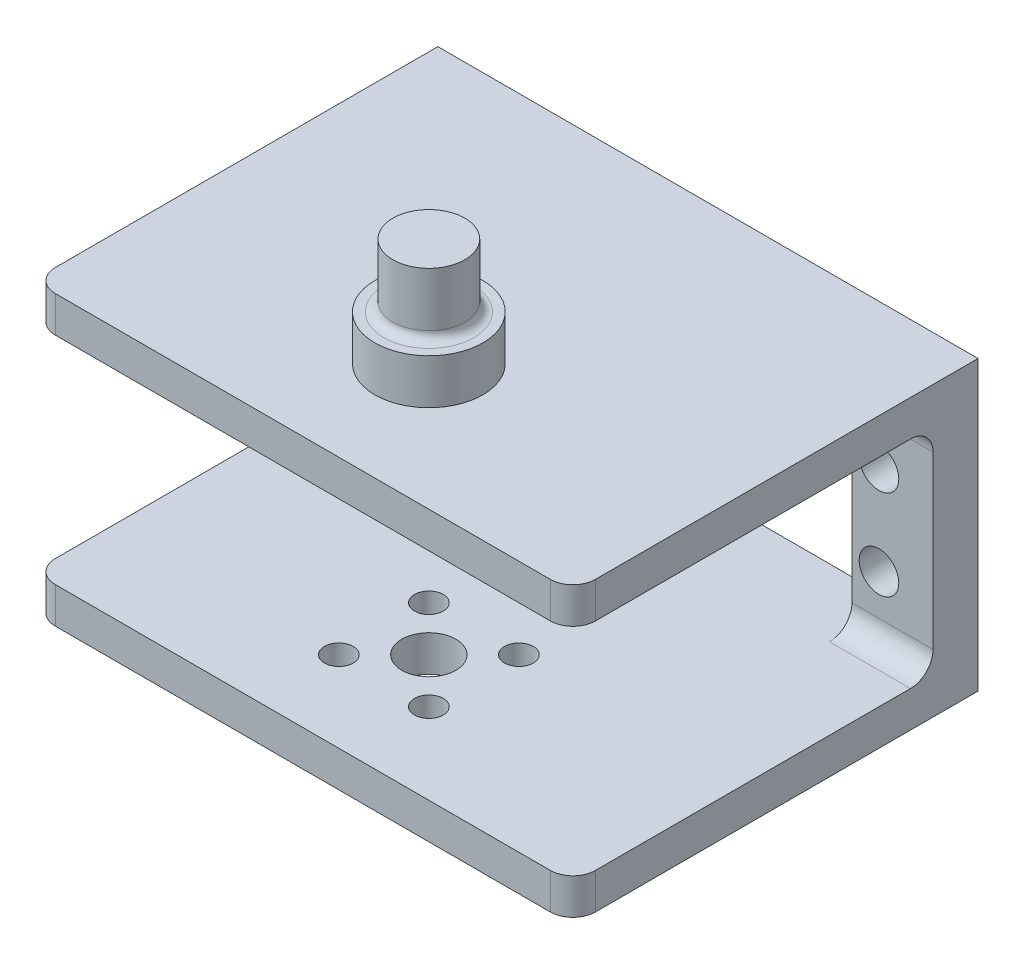
from build123d import *

# Parameters (mm, degrees)
SKETCH1_W           = 60
SKETCH1_H           = 4
BOSS_EXTRUDE1_DEPTH = 45
SKETCH1_3_W         = 9
SKETCH1_3_H         = 24
SKETCH1_3_R         = 2.2
BOSS_EXTRUDE2_DEPTH = 5
SKETCH2_R           = 3
SKETCH2_R_2         = 1.6
CUT_EXTRUDE1_DEPTH  = 124.088359511
BOSS_EXTRUDE3_DEPTH = 45
FILLET1_R           = 2.5
FILLET3_R           = 2.5
SKETCH3_R           = 4
BOSS_EXTRUDE4_DEPTH = 12
SKETCH4_R           = 6
BOSS_EXTRUDE5_DEPTH = 5
FILLET4_R           = 1


with BuildPart() as part:
    # Sketch1 → Boss-Extrude1 (new body)
    with BuildSketch(Plane.XY):
        with Locations((-82.025641026, 5.685176195)):
            Rectangle(SKETCH1_W, SKETCH1_H)
    extrude(amount=BOSS_EXTRUDE1_DEPTH)

    # Sketch1_3 → Boss-Extrude2 (add)
    # profile 1 of 2: a face of its own
    with BuildSketch(Plane.XY):
        with Locations((-107.525641026, 19.685176195)):
            Rectangle(SKETCH1_3_W, SKETCH1_3_H)
        with Locations((-106.025641026, 14.685176195)):
            Circle(SKETCH1_3_R, mode=Mode.SUBTRACT)
        with Locations((-106.025641026, 24.685176195)):
            Circle(SKETCH1_3_R, mode=Mode.SUBTRACT)
    # profile 2 of 2: a face of its own
    with BuildSketch(Plane.XY):
        with Locations((-56.525641026, 19.685176195)):
            Rectangle(SKETCH1_3_W, SKETCH1_3_H)
        with Locations((-58.025641026, 14.685176195)):
            Circle(SKETCH1_3_R, mode=Mode.SUBTRACT)
        with Locations((-58.025641026, 24.685176195)):
            Circle(SKETCH1_3_R, mode=Mode.SUBTRACT)
    extrude(amount=BOSS_EXTRUDE2_DEPTH)

    # Sketch2 → Cut-Extrude1 (cut, through all)
    with BuildSketch(Plane(origin=(0, 7.685176195, 0), x_dir=(1, 0, 0), z_dir=(0, 1, 0))):
        with Locations((-82.025641026, -31)):
            Circle(SKETCH2_R)
        with Locations((-77.025641026, -26)):
            Circle(SKETCH2_R_2)
        with Locations((-87.025641026, -26)):
            Circle(SKETCH2_R_2)
        with Locations((-77.025641026, -36)):
            Circle(SKETCH2_R_2)
        with Locations((-87.025641026, -36)):
            Circle(SKETCH2_R_2)
    extrude(amount=-CUT_EXTRUDE1_DEPTH, mode=Mode.SUBTRACT)

    # Sketch1_4 → Boss-Extrude3 (add)
    with BuildSketch(Plane.XY):
        Polygon((-112.025641026, 35.685176195), (-112.025641026, 31.685176195), (-103.025641026, 31.685176195), (-61.025641026, 31.685176195), (-52.025641026, 31.685176195), (-52.025641026, 35.685176195), align=None)
    extrude(amount=BOSS_EXTRUDE3_DEPTH)

    # Fillet1
    fillet1_edges = [part.edges().sort_by_distance(p)[0] for p in [
        (-52.025641026, 5.685176195, 45),
        (-112.025641026, 5.685176195, 45),
        (-52.025641026, 33.685176195, 45),
        (-112.025641026, 33.685176195, 45),
    ]]
    fillet(fillet1_edges, radius=FILLET1_R)

    # Fillet3
    fillet3_edges = [part.edges().sort_by_distance(p)[0] for p in [
        (-107.525641026, 7.685176195, 5),
        (-56.525641026, 7.685176195, 5),
        (-56.525641026, 31.685176195, 5),
        (-107.525641026, 31.685176195, 5),
    ]]
    fillet(fillet3_edges, radius=FILLET3_R)

    # Sketch3 → Boss-Extrude4 (add)
    with BuildSketch(Plane(origin=(0, 35.685176195, 0), x_dir=(1, 0, 0), z_dir=(0, 1, 0))):
        with Locations((-82.025641026, -31)):
            Circle(SKETCH3_R)
    extrude(amount=BOSS_EXTRUDE4_DEPTH)

    # Sketch4 → Boss-Extrude5 (add)
    with BuildSketch(Plane(origin=(0, 35.685176195, 0), x_dir=(1, 0, 0), z_dir=(0, 1, 0))):
        with Locations((-82.025641026, -31)):
            Circle(SKETCH4_R)
    extrude(amount=BOSS_EXTRUDE5_DEPTH)

    # Fillet4
    fillet4_edges = [part.edges().sort_by_distance(p)[0] for p in [
        (-86.025641026, 40.685176195, 31),
    ]]
    fillet(fillet4_edges, radius=FILLET4_R)


solid = part.part
